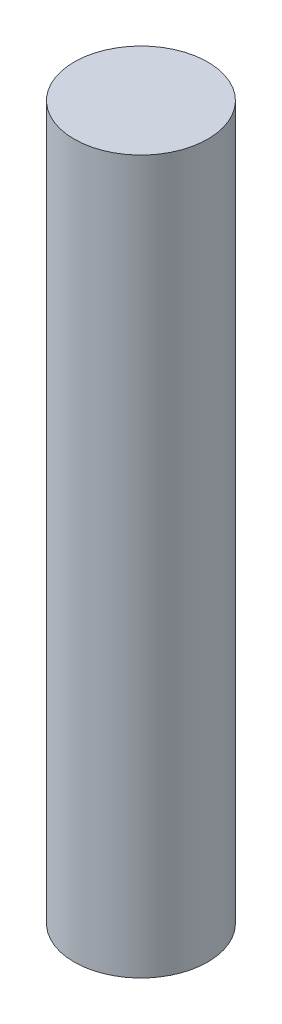
from build123d import *

# Parameters (mm, degrees)
SKETCH1_R           = 4.7625
BOSS_EXTRUDE1_DEPTH = 50.8


with BuildPart() as part:
    # Sketch1 → Boss-Extrude1 (new body)
    with BuildSketch(Plane(origin=(0, 0, 0), x_dir=(1, 0, 0), z_dir=(0, 1, 0))):
        Circle(SKETCH1_R)
    extrude(amount=BOSS_EXTRUDE1_DEPTH)


solid = part.part
